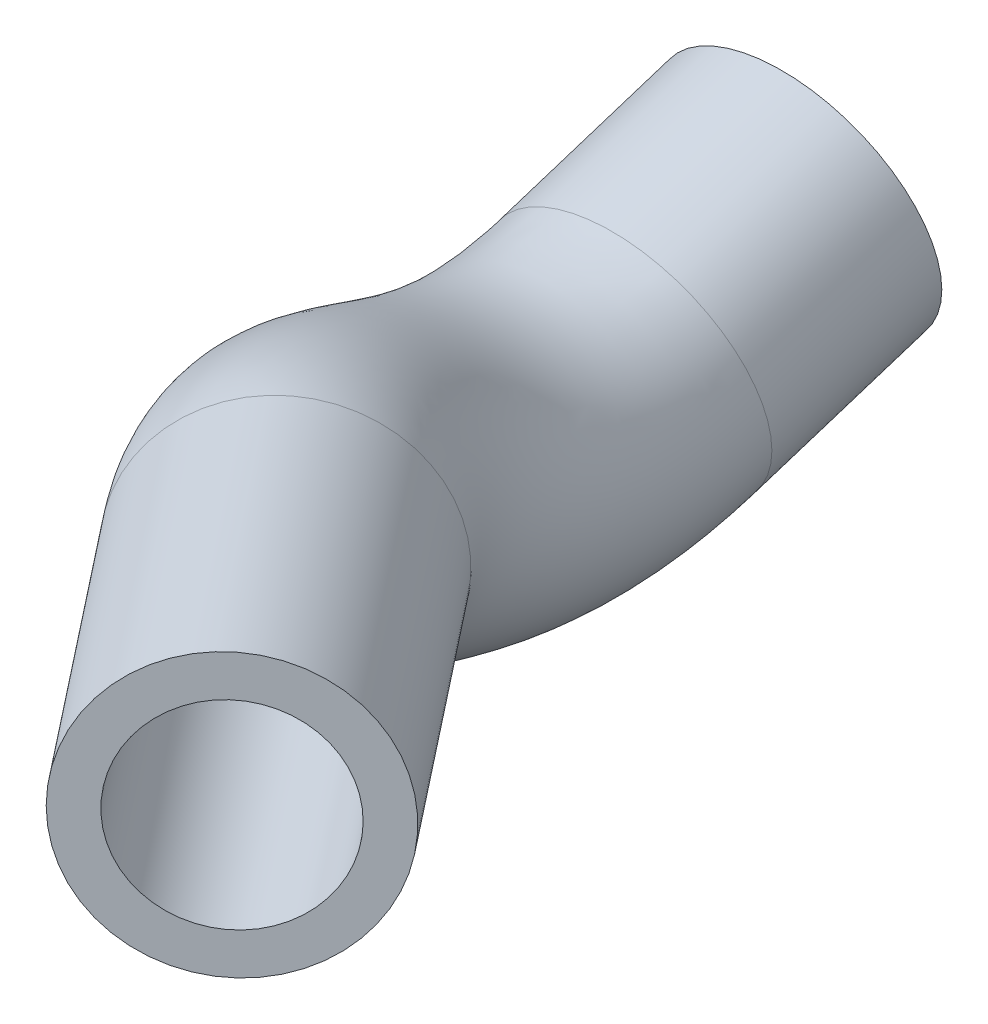
from build123d import *

# Parameters (mm, degrees)
SWEEP1_PROFILE_R     = 13.49375
CUT_SWEEP1_PROFILE_R = 9.525


with BuildPart() as part:
    # Sweep1: sweep along a curve in space
    with BuildLine() as sweep1_path:
        Line((144.16623583, 29.78638886, -53.357198813), (145.299475263, 25.359683675, -34.863347144))
        add(Edge.make_bspline(
            [(145.299475263, 25.359683675, -34.863347144), (146.690863379, 19.924587782, -12.156649263), (145.49252871, 34.79865885, -2.165117432), (157.129656366, 36.72827895, 12.110093025)],
            knots=[0, 0, 0, 0, 1, 1, 1, 1], degree=3))
        Line((157.129656366, 36.72827895, 12.110093025), (181.072152323, 40.698324032, 41.480241636))
    # Sweep1 profile (on start of the path) → Sweep1 (sweep)
    with BuildSketch(Plane(origin=(144.16623583, 29.78638886, -53.357198813), x_dir=(0, 0.9725281679518014, 0.23278522835505014), z_dir=(0.059487634281804834, -0.23237297561799386, 0.9708058619363572))):
        Circle(SWEEP1_PROFILE_R)
    sweep(path=sweep1_path.line)

    # Cut-Sweep1: sweep along a curve in space
    with BuildLine() as cut_sweep1_path:
        Line((144.16623583, 29.78638886, -53.357198813), (145.299475263, 25.359683675, -34.863347144))
        add(Edge.make_bspline(
            [(145.299475263, 25.359683675, -34.863347144), (146.690863379, 19.924587782, -12.156649263), (145.49252871, 34.79865885, -2.165117432), (157.129656366, 36.72827895, 12.110093025)],
            knots=[0, 0, 0, 0, 1, 1, 1, 1], degree=3))
        Line((157.129656366, 36.72827895, 12.110093025), (181.072152323, 40.698324032, 41.480241636))
    # Cut-Sweep1 profile (on start of the path) → Cut-Sweep1 (sweep, cut)
    with BuildSketch(Plane(origin=(144.16623583, 29.78638886, -53.357198813), x_dir=(0, 0.9725281679518014, 0.23278522835505014), z_dir=(0.059487634281804834, -0.23237297561799386, 0.9708058619363572))):
        Circle(CUT_SWEEP1_PROFILE_R)
    sweep(path=cut_sweep1_path.line, mode=Mode.SUBTRACT)


solid = part.part
